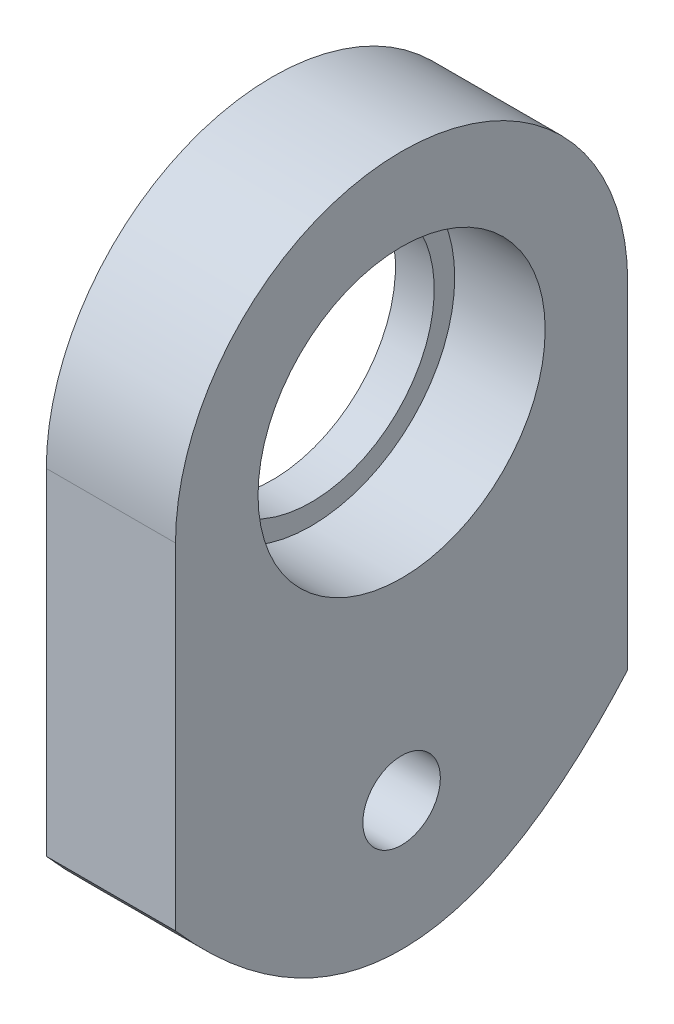
from build123d import *

# Parameters (mm, degrees)
CROQUIS1_R              = 2.5
SALIENTE_EXTRUIR2_DEPTH = 10
CROQUIS2_R              = 17.5
CROQUIS2_R_2            = 11.1125
SALIENTE_EXTRUIR3_DEPTH = 10
CROQUIS3_R              = 11.1125
CORTAR_EXTRUIR1_DEPTH   = 10
CROQUIS4_R              = 11.1125
CROQUIS4_R_2            = 9.525
SALIENTE_EXTRUIR4_DEPTH = 3
CROQUIS5_R              = 3
CORTAR_EXTRUIR2_DEPTH   = 10


with BuildPart() as part:
    # Croquis1 → Saliente-Extruir2 (new body)
    with BuildSketch(Plane(origin=(0, 0, 0), x_dir=(0, 0, -1), z_dir=(1, 0, 0))):
        with BuildLine():
            Line((17.5, -26), (17.5, 0))
            ThreePointArc((17.5, 0), (0, 17.5), (-17.5, 0))
            Line((-17.5, 0), (-17.5, -26))
            add(Edge.make_bspline(
                [(-17.5, -26), (0, -46), (17.5, -26)],
                knots=[0, 0, 0, 1, 1, 1], degree=2))
        make_face()
        with Locations((0, -26)):
            Circle(CROQUIS1_R, mode=Mode.SUBTRACT)
        with BuildLine():
            Line((-13.783729421, -3.874119675), (-3.536778655, 13.874119675))
            ThreePointArc((-3.536778655, 13.874119675), (-2.922822403, 14.532391234), (-2.082378285, 14.854753471))
            ThreePointArc((-2.082378285, 14.854753471), (0, 15), (2.082378285, 14.854753471))
            ThreePointArc((2.082378285, 14.854753471), (2.922822403, 14.532391234), (3.536778655, 13.874119675))
            Line((3.536778655, 13.874119675), (13.783729421, -3.874119675))
            ThreePointArc((13.783729421, -3.874119675), (14.046831188, -4.734957166), (13.905783015, -5.62398424))
            ThreePointArc((13.905783015, -5.62398424), (12.990381057, -7.5), (11.82340473, -9.230769231))
            ThreePointArc((11.82340473, -9.230769231), (11.124008785, -9.797434069), (10.246950766, -10))
            Line((10.246950766, -10), (-10.246950766, -10))
            ThreePointArc((-10.246950766, -10), (-11.124008785, -9.797434069), (-11.82340473, -9.230769231))
            ThreePointArc((-11.82340473, -9.230769231), (-12.990381057, -7.5), (-13.905783015, -5.62398424))
            ThreePointArc((-13.905783015, -5.62398424), (-14.046831188, -4.734957166), (-13.783729421, -3.874119675))
        make_face(mode=Mode.SUBTRACT)
    extrude(amount=SALIENTE_EXTRUIR2_DEPTH)

    # Croquis2 → Saliente-Extruir3 (add)
    with BuildSketch(Plane.ZY):
        Circle(CROQUIS2_R)
        Circle(CROQUIS2_R_2, mode=Mode.SUBTRACT)
    extrude(amount=-SALIENTE_EXTRUIR3_DEPTH)

    # Croquis3 → Cortar-Extruir1 (cut)
    with BuildSketch(Plane.ZY):
        Circle(CROQUIS3_R)
    extrude(amount=-CORTAR_EXTRUIR1_DEPTH, mode=Mode.SUBTRACT)

    # Croquis4 → Saliente-Extruir4 (add)
    with BuildSketch(Plane.ZY):
        Circle(CROQUIS4_R)
        Circle(CROQUIS4_R_2, mode=Mode.SUBTRACT)
    extrude(amount=-SALIENTE_EXTRUIR4_DEPTH)

    # Croquis5 → Cortar-Extruir2 (cut)
    with BuildSketch(Plane(origin=(10, 0, 0), x_dir=(0, 0, -1), z_dir=(1, 0, 0))):
        with Locations((0, -26)):
            Circle(CROQUIS5_R)
    extrude(amount=-CORTAR_EXTRUIR2_DEPTH, mode=Mode.SUBTRACT)


solid = part.part
